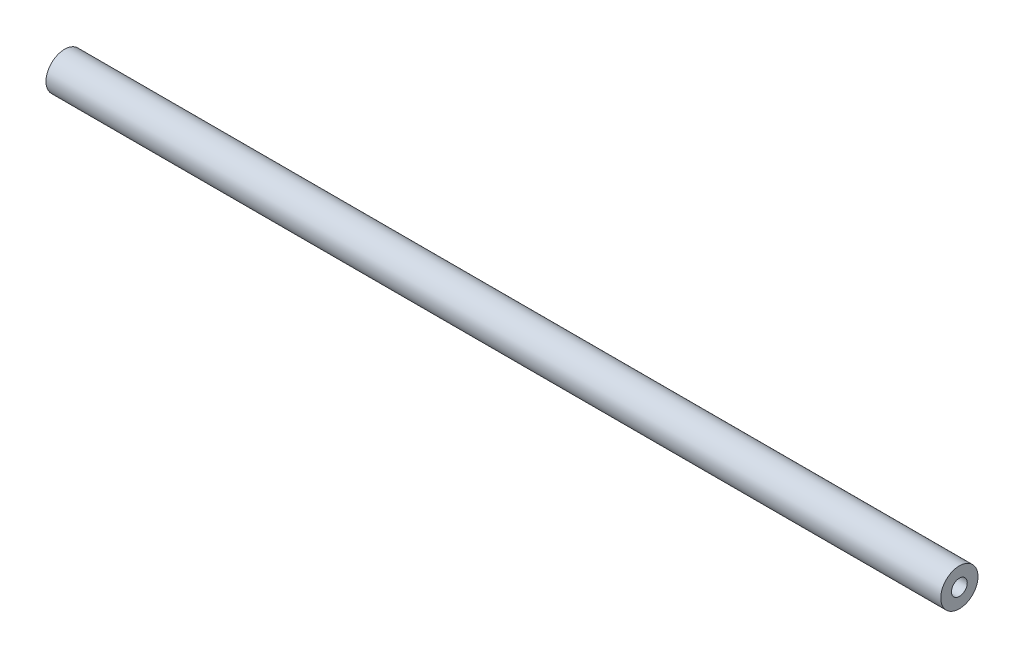
from build123d import *

# Parameters (mm, degrees)
SKETCH1_R                  = 4.7625
BOSS_EXTRUDE1_DEPTH        = 114.3
F_10_32_TAPPED_HOLE1_D     = 4.0386
F_10_32_TAPPED_HOLE1_DEPTH = 11.938


with BuildPart() as part:
    # Sketch1 → Boss-Extrude1 (new body, symmetric)
    with BuildSketch(Plane(origin=(0, 0, 0), x_dir=(0, 0, -1), z_dir=(1, 0, 0))):
        Circle(SKETCH1_R)
    extrude(amount=BOSS_EXTRUDE1_DEPTH, both=True)

    # #10-32 Tapped Hole1
    with Locations(Plane.ZY.offset(114.3)):
        with Locations((0, 0)):
            f_10_32_tapped_hole1 = Hole(F_10_32_TAPPED_HOLE1_D / 2, depth=F_10_32_TAPPED_HOLE1_DEPTH)

    # Mirror1: #10-32 Tapped Hole1 across plane
    add(f_10_32_tapped_hole1.mirror(Plane(origin=(0, 0, 0), x_dir=(0, 0, 1), z_dir=(1, 0, 0))), mode=Mode.SUBTRACT)


solid = part.part
